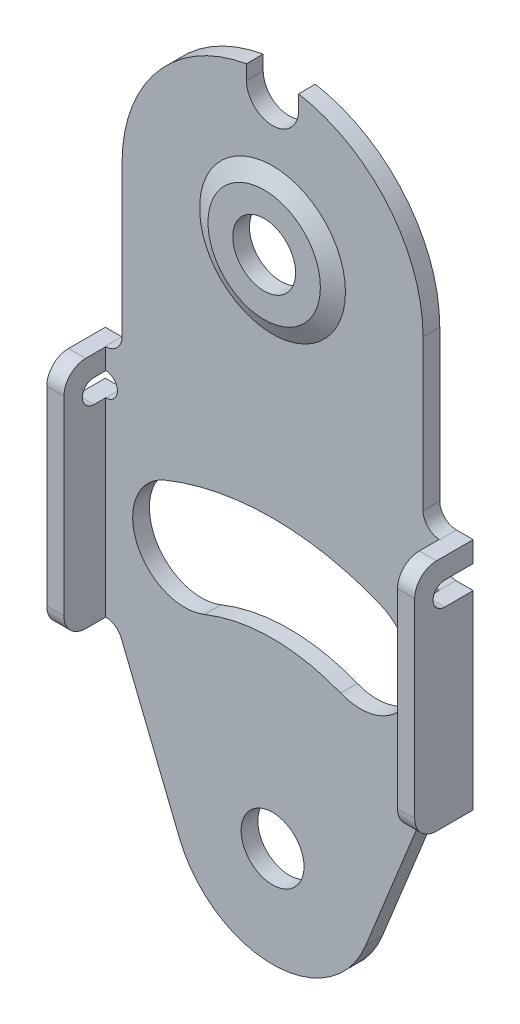
from build123d import *

# Parameters (mm, degrees)
SKETCH1_R          = 2.3876
EXTRUDE1_DEPTH     = 1.27
SKETCH2_W          = 1.303146297
SKETCH2_H          = 17.78
EXTRUDE2_DEPTH     = 3.175
SKETCH3_R          = 5.5372
SKETCH3_R_2        = 2.3876
EXTRUDE3_DEPTH     = 0.635
CUT_EXTRUDE1_DEPTH = 2.27
CUT_EXTRUDE2_DEPTH = 1.3208
SKETCH7_W          = 0.407051282
SKETCH7_H          = 0.108547009
SKETCH7_W_2        = 0.094978633
SKETCH7_H_2        = 1.058333333
CUT_EXTRUDE3_DEPTH = 0.00254
FILLET1_R          = 1.651


with BuildPart() as part:
    # Sketch1 → Extrude1 (new body)
    with BuildSketch(Plane.XY):
        with BuildLine():
            Line((12.666853703, 8.89), (13.97, 8.89))
            Line((13.97, 8.89), (13.97, 26.67))
            Line((13.97, 26.67), (12.7, 26.67))
            ThreePointArc((12.7, 26.67), (11.801974389, 27.041974387), (11.43, 27.939999996))
            Line((11.43, 27.939999996), (11.43, 39.37))
            ThreePointArc((11.43, 39.37), (8.754713473, 46.71846188), (1.9812, 50.626986567))
            Line((1.9812, 50.626986567), (1.9812, 49.53))
            ThreePointArc((1.9812, 49.53), (0, 47.5488), (-1.9812, 49.53))
            Line((-1.9812, 49.53), (-1.9812, 50.626986567))
            ThreePointArc((-1.9812, 50.626986567), (-8.754713473, 46.71846188), (-11.43, 39.37))
            Line((-11.43, 39.37), (-11.43, 27.939999996))
            ThreePointArc((-11.43, 27.939999996), (-11.801974389, 27.041974387), (-12.7, 26.67))
            Line((-12.7, 26.67), (-13.97, 26.67))
            Line((-13.97, 26.67), (-13.97, 8.89))
            Line((-13.97, 8.89), (-12.666853703, 8.89))
            ThreePointArc((-12.666853703, 8.89), (-11.956678716, 8.672877717), (-11.489330208, 8.095750374))
            Line((-11.489330208, 8.095750374), (-7.065140972, -2.854502242))
            ThreePointArc((-7.065140972, -2.854502242), (0, -7.62), (7.065140972, -2.854502242))
            Line((7.065140972, -2.854502242), (11.489330208, 8.095750374))
            ThreePointArc((11.489330208, 8.095750374), (11.956678716, 8.672877717), (12.666853703, 8.89))
        make_face()
        Circle(SKETCH1_R, mode=Mode.SUBTRACT)
        with Locations((0, 39.37)):
            Circle(SKETCH1_R, mode=Mode.SUBTRACT)
    extrude(amount=EXTRUDE1_DEPTH)

    # Sketch2 → Extrude2 (add)
    with BuildSketch(Plane.XY.offset(1.27)):
        with Locations((-13.318426851, 17.78)):
            Rectangle(SKETCH2_W, SKETCH2_H)
        with Locations((13.318426851, 17.78)):
            Rectangle(SKETCH2_W, SKETCH2_H)
    extrude(amount=EXTRUDE2_DEPTH)

    # Sketch3 → Extrude3 (add)
    with BuildSketch(Plane.XY.offset(1.27)):
        with Locations((0, 39.37)):
            Circle(SKETCH3_R)
        with Locations((0, 39.37)):
            Circle(SKETCH3_R_2, mode=Mode.SUBTRACT)
    extrude(amount=EXTRUDE3_DEPTH)

    # Sketch4 → Cut-Revolve1 (revolve, cut)
    with BuildSketch(Plane(origin=(0, 0, 0), x_dir=(0, 0, -1), z_dir=(1, 0, 0))):
        Polygon((-1.905, 43.6372), (-1.27, 44.9072), (-1.905, 44.9072), align=None)
        Polygon((-0.635, 43.3324), (-0.635, 41.7576), (0, 41.7576), (0, 43.3324), (0, 44.5389), align=None)
    revolve(axis=Axis((0, 39.37, 6.286624189), (0, 0, -1)), mode=Mode.SUBTRACT)

    # Sketch5 → Cut-Extrude1 (cut, through all)
    with BuildSketch(Plane.XY.offset(1.27)):
        with BuildLine():
            Line((-12.666853703, 25.0952), (-12.666853703, 23.3172))
            ThreePointArc((-12.666853703, 23.3172), (-11.777853703, 24.2062), (-12.666853703, 25.0952))
        make_face()
        with BuildLine():
            Line((12.666853703, 25.0952), (12.666853703, 23.3172))
            ThreePointArc((12.666853703, 23.3172), (11.777853703, 24.2062), (12.666853703, 25.0952))
        make_face()
        with BuildLine():
            ThreePointArc((5.176164065, 12.811455629), (0, 13.8176), (-5.176164065, 12.811455629))
            ThreePointArc((-5.176164065, 12.811455629), (-10.334378536, 15.000987768), (-8.144846397, 20.15920224))
            ThreePointArc((-8.144846397, 20.15920224), (0, 21.7424), (8.144846397, 20.15920224))
            ThreePointArc((8.144846397, 20.15920224), (10.334378536, 15.000987768), (5.176164065, 12.811455629))
        make_face()
    extrude(amount=-CUT_EXTRUDE1_DEPTH, mode=Mode.SUBTRACT)

    # Sketch6 → Cut-Extrude2 (cut)
    with BuildSketch(Plane(origin=(13.97, 0, 0), x_dir=(0, 0, -1), z_dir=(1, 0, 0))):
        with BuildLine():
            Line((0, 25.0952), (-2.159, 25.0952))
            ThreePointArc((-2.159, 25.0952), (-3.048, 24.2062), (-2.159, 23.3172))
            Line((-2.159, 23.3172), (0, 23.3172))
            Line((0, 23.3172), (0, 25.0952))
        make_face()
    cut_extrude2 = extrude(amount=-CUT_EXTRUDE2_DEPTH, mode=Mode.SUBTRACT)

    # Mirror2: Cut-Extrude2 across plane
    add(cut_extrude2.mirror(Plane(origin=(0, 0, 0), x_dir=(0, 0, 1), z_dir=(1, 0, 0))), mode=Mode.SUBTRACT)

    # Sketch7 → Cut-Extrude3 (cut)
    with BuildSketch(Plane(origin=(0, 0, 0), x_dir=(-1, 0, 0), z_dir=(0, 0, -1))):
        Polygon((-7.47529818, 7.634015825), (-7.377139459, 7.634015825), (-7.170009718, 6.857862313), (-6.861965181, 7.634015825), (-6.848184799, 7.634015825), (-6.545864419, 6.86316246), (-6.337674649, 7.634015825), (-6.240575958, 7.634015825), (-6.525935867, 6.575682492), (-6.539504243, 6.575682492), (-6.857937069, 7.385120926), (-7.180186, 6.575682492), (-7.193754377, 6.575682492), align=None)
        Polygon((-6.118460573, 7.634015825), (-6.020301853, 7.634015825), (-5.813172112, 6.857862313), (-5.505127574, 7.634015825), (-5.491347192, 7.634015825), (-5.189026812, 6.86316246), (-4.980837042, 7.634015825), (-4.883738351, 7.634015825), (-5.16909826, 6.575682492), (-5.182666636, 6.575682492), (-5.501099462, 7.385120926), (-5.823348394, 6.575682492), (-5.83691677, 6.575682492), align=None)
        Polygon((-4.761622966, 7.634015825), (-4.663464246, 7.634015825), (-4.456334505, 6.857862313), (-4.148289967, 7.634015825), (-4.134509585, 7.634015825), (-3.832189206, 6.86316246), (-3.623999435, 7.634015825), (-3.526900744, 7.634015825), (-3.812260653, 6.575682492), (-3.825829029, 6.575682492), (-4.144261855, 7.385120926), (-4.466510787, 6.575682492), (-4.480079163, 6.575682492), align=None)
        with BuildLine():
            add(Edge.make_bspline(
                [(-3.262317411, 6.738503004), (-3.256423942, 6.738152797), (-3.244870485, 6.737466256), (-3.228167225, 6.732756167), (-3.213049792, 6.724392714), (-3.199584089, 6.713246112), (-3.18848475, 6.699730995), (-3.179823244, 6.684734137), (-3.175154184, 6.667891036), (-3.174472644, 6.656270635), (-3.174122966, 6.65030856)],
                knots=[0, 0, 0, 0, 1.7678e-05, 3.4656e-05, 5.1542e-05, 6.9159e-05, 8.6776e-05, 0.000103764, 0.000120742, 0.000138631, 0.000138631, 0.000138631, 0.000138631], degree=3))
            add(Edge.make_bspline(
                [(-3.174122966, 6.65030856), (-3.174484493, 6.644489744), (-3.175197419, 6.633015123), (-3.179812541, 6.616299062), (-3.188550761, 6.601292831), (-3.199507533, 6.587594328), (-3.213053121, 6.576424112), (-3.228202965, 6.568131815), (-3.244831274, 6.563084478), (-3.2564174, 6.562441526), (-3.262317411, 6.562114116)],
                knots=[0, 0, 0, 0, 1.7467e-05, 3.4445e-05, 5.1433e-05, 6.9214e-05, 8.6831e-05, 0.000103717, 0.000120754, 0.000138432, 0.000138432, 0.000138432, 0.000138432], degree=3))
            add(Edge.make_bspline(
                [(-3.262317411, 6.562114116), (-3.268221673, 6.562429679), (-3.279748339, 6.563045743), (-3.29631458, 6.568235449), (-3.311556687, 6.576346352), (-3.325099638, 6.587615156), (-3.336148176, 6.601222342), (-3.344501565, 6.616402409), (-3.34951811, 6.632967272), (-3.350177867, 6.644480319), (-3.350511855, 6.65030856)],
                knots=[0, 0, 0, 0, 1.7678e-05, 3.4512e-05, 5.1585e-05, 6.9202e-05, 8.6983e-05, 0.000103869, 0.000120906, 0.000138373, 0.000138373, 0.000138373, 0.000138373], degree=3))
            add(Edge.make_bspline(
                [(-3.350511855, 6.65030856), (-3.350190697, 6.656280396), (-3.349563674, 6.667939674), (-3.344491034, 6.684630832), (-3.336212989, 6.699800813), (-3.325023262, 6.713225493), (-3.311559963, 6.724470225), (-3.296351349, 6.732654103), (-3.27970844, 6.737504418), (-3.268214959, 6.738164369), (-3.262317411, 6.738503004)],
                knots=[0, 0, 0, 0, 1.7889e-05, 3.4926e-05, 5.1812e-05, 6.9429e-05, 8.7046e-05, 0.000104119, 0.000120893, 0.000138571, 0.000138571, 0.000138571, 0.000138571], degree=3))
        make_face()
        Polygon((-3.02487083, 7.634015825), (-2.916111815, 7.634015825), (-2.637960106, 7.179263221), (-2.360232408, 7.634015825), (-2.251473394, 7.634015825), (-2.590682795, 7.078772436), (-2.590682795, 6.575682492), (-2.685661428, 6.575682492), (-2.685661428, 7.078772436), align=None)
        with BuildLine():
            add(Edge.make_bspline(
                [(-1.566270402, 7.661152577), (-1.546673665, 7.660656225), (-1.508184058, 7.659681349), (-1.451616172, 7.652218858), (-1.397612417, 7.639308585), (-1.345732875, 7.622114302), (-1.296598094, 7.599177381), (-1.249838238, 7.571453538), (-1.205564564, 7.538652324), (-1.164373813, 7.501027295), (-1.126679926, 7.460089918), (-1.09347067, 7.41640255), (-1.065638834, 7.37022934), (-1.042783131, 7.321709042), (-1.024852361, 7.270951385), (-1.012479222, 7.21768577), (-1.004575543, 7.162257318), (-1.003651534, 7.124451576), (-1.003182795, 7.10527317)],
                knots=[0, 0, 0, 0, 5.8781e-05, 0.00011545, 0.000170782, 0.000225153, 0.000279125, 0.000333119, 0.000387987, 0.000444118, 0.000500236, 0.000554722, 0.00060846, 0.000661664, 0.000715372, 0.000769623, 0.000825481, 0.00088299, 0.00088299, 0.00088299, 0.00088299], degree=3))
            add(Edge.make_bspline(
                [(-1.003182795, 7.10527317), (-1.003651465, 7.086236037), (-1.004575268, 7.048711644), (-1.012488208, 6.993634936), (-1.024898225, 6.940690844), (-1.04261662, 6.889967754), (-1.065363372, 6.841412157), (-1.09338053, 6.795151816), (-1.126382754, 6.751171566), (-1.16394054, 6.709953212), (-1.204883236, 6.672156358), (-1.248798102, 6.639221364), (-1.294697511, 6.610880974), (-1.343172113, 6.588267816), (-1.393579029, 6.570193926), (-1.446369398, 6.557871107), (-1.501295856, 6.549922405), (-1.538752088, 6.549009664), (-1.557790167, 6.54854574)],
                knots=[0, 0, 0, 0, 5.7086e-05, 0.000112524, 0.000166569, 0.000220006, 0.000273402, 0.00032714, 0.000381965, 0.000438096, 0.000494214, 0.00054887, 0.000602537, 0.000655741, 0.000709049, 0.000762887, 0.000818115, 0.000875201, 0.000875201, 0.000875201, 0.000875201], degree=3))
            add(Edge.make_bspline(
                [(-1.557790167, 6.54854574), (-1.576968473, 6.549014245), (-1.614774019, 6.549937793), (-1.670272123, 6.557854551), (-1.723575155, 6.570234421), (-1.774530685, 6.58792656), (-1.823167128, 6.610791771), (-1.869579605, 6.638672619), (-1.913581824, 6.671755254), (-1.954808971, 6.709300861), (-1.992530752, 6.750174164), (-2.025417516, 6.793969284), (-2.053304633, 6.839827005), (-2.07609307, 6.88787459), (-2.094134466, 6.937879764), (-2.106442827, 6.99017609), (-2.114406318, 7.044465416), (-2.115323997, 7.08142934), (-2.115789633, 7.100185029)],
                knots=[0, 0, 0, 0, 5.751e-05, 0.000113367, 0.000167825, 0.000221463, 0.000274858, 0.000328778, 0.000383603, 0.000439735, 0.000495852, 0.000550211, 0.000603768, 0.000656588, 0.000709497, 0.000762923, 0.000817521, 0.00087376, 0.00087376, 0.00087376, 0.00087376], degree=3))
            add(Edge.make_bspline(
                [(-2.115789633, 7.100185029), (-2.115627969, 7.112773955), (-2.115306682, 7.137792993), (-2.111438717, 7.174945512), (-2.105826013, 7.211500544), (-2.097782101, 7.247354141), (-2.087261764, 7.282418534), (-2.074848412, 7.31693555), (-2.059687078, 7.35055539), (-2.04254793, 7.383437321), (-2.023418764, 7.415068759), (-2.002289668, 7.444968061), (-1.979902783, 7.473386125), (-1.955360519, 7.499586528), (-1.929471737, 7.524331467), (-1.901816465, 7.54724067), (-1.872563453, 7.568520714), (-1.841586829, 7.587697817), (-1.809649874, 7.605042127), (-1.776727611, 7.619925877), (-1.743267171, 7.632700282), (-1.709111837, 7.643054055), (-1.674352308, 7.651228028), (-1.638912721, 7.656794061), (-1.602821309, 7.66067189), (-1.578506458, 7.660991659), (-1.566270402, 7.661152577)],
                knots=[0, 0, 0, 0, 3.7752e-05, 7.5028e-05, 0.000111939, 0.000148663, 0.000185154, 0.000221705, 0.000258622, 0.0002957, 0.000332895, 0.000369421, 0.000405477, 0.000441331, 0.000477021, 0.000512852, 0.000548983, 0.000585456, 0.000622071, 0.000657934, 0.000693765, 0.000729444, 0.000764928, 0.000800792, 0.000837013, 0.000873706, 0.000873706, 0.000873706, 0.000873706], degree=3))
        make_face()
        with BuildLine():
            add(Edge.make_bspline(
                [(-1.561606273, 7.552605569), (-1.571649745, 7.552483137), (-1.591640674, 7.552239446), (-1.621360046, 7.549029456), (-1.650688559, 7.544454465), (-1.679632271, 7.537928625), (-1.708070078, 7.529037399), (-1.736267053, 7.518804553), (-1.763966072, 7.50634008), (-1.791075691, 7.492257382), (-1.817357154, 7.47666997), (-1.842156233, 7.459442793), (-1.865537128, 7.440979849), (-1.887442592, 7.42123805), (-1.907808303, 7.400116861), (-1.927035106, 7.377936482), (-1.944352337, 7.354062934), (-1.960222975, 7.329143597), (-1.974425155, 7.303210928), (-1.987054203, 7.276537946), (-1.997384749, 7.248907074), (-2.005809801, 7.220618079), (-2.012794743, 7.191715763), (-2.017219763, 7.161980876), (-2.020465024, 7.13156283), (-2.020694787, 7.111006412), (-2.020811, 7.100609041)],
                knots=[0, 0, 0, 0, 3.0117e-05, 5.9946e-05, 8.9572e-05, 0.000119144, 0.000148853, 0.000178903, 0.000209082, 0.0002399, 0.000270514, 0.000300683, 0.000330416, 0.000359836, 0.000389072, 0.000418391, 0.00044782, 0.000477462, 0.00050697, 0.000536467, 0.00056592, 0.000595365, 0.000624985, 0.00065503, 0.000685492, 0.000716668, 0.000716668, 0.000716668, 0.000716668], degree=3))
            add(Edge.make_bspline(
                [(-2.020811, 7.100609041), (-2.020425507, 7.085319988), (-2.019667121, 7.055241692), (-2.01302757, 7.011164182), (-2.002800449, 6.968804153), (-1.987724531, 6.928393385), (-1.968870893, 6.889584518), (-1.945579428, 6.85272183), (-1.917984419, 6.817795356), (-1.886638543, 6.785048929), (-1.852371915, 6.755159841), (-1.81598559, 6.728924239), (-1.77786938, 6.706726377), (-1.737923888, 6.688642463), (-1.69636237, 6.674312708), (-1.652917015, 6.664491789), (-1.607877233, 6.658028259), (-1.577176297, 6.657407544), (-1.561606273, 6.657092748)],
                knots=[0, 0, 0, 0, 4.5842e-05, 9.0186e-05, 0.00013343, 0.000176357, 0.000219309, 0.000262659, 0.000306895, 0.00035263, 0.000398461, 0.000443118, 0.000487007, 0.000530556, 0.00057447, 0.000618645, 0.000664009, 0.00071069, 0.00071069, 0.00071069, 0.00071069], degree=3))
            add(Edge.make_bspline(
                [(-1.561606273, 6.657092748), (-1.551141019, 6.657236532), (-1.530385277, 6.657521697), (-1.499513536, 6.660393916), (-1.469197967, 6.664999743), (-1.439481092, 6.671631156), (-1.410396637, 6.679930668), (-1.381823208, 6.689790624), (-1.354065154, 6.702091845), (-1.326772298, 6.71568325), (-1.30064772, 6.731177297), (-1.27570869, 6.747819786), (-1.252583811, 6.766255535), (-1.230694734, 6.785704017), (-1.210245409, 6.806557371), (-1.191374121, 6.828788485), (-1.174144415, 6.852537684), (-1.158279802, 6.877419223), (-1.144127387, 6.903422852), (-1.131796564, 6.93019254), (-1.121335358, 6.957662371), (-1.11289031, 6.985871965), (-1.106272563, 7.014767746), (-1.101712683, 7.044388403), (-1.098523036, 7.07467468), (-1.09828262, 7.095159132), (-1.098161428, 7.105485176)],
                knots=[0, 0, 0, 0, 3.1388e-05, 6.2252e-05, 9.2926e-05, 0.000123326, 0.000153524, 0.00018363, 0.000213918, 0.000244542, 0.000275048, 0.000304978, 0.000334413, 0.000363692, 0.000392777, 0.000421958, 0.00045109, 0.000480732, 0.000510427, 0.000539834, 0.000569089, 0.000598533, 0.000628106, 0.000657941, 0.000688403, 0.000719368, 0.000719368, 0.000719368, 0.000719368], degree=3))
            add(Edge.make_bspline(
                [(-1.098161428, 7.105485176), (-1.098282717, 7.115740578), (-1.098523316, 7.136084058), (-1.101711159, 7.166159115), (-1.106277381, 7.195566634), (-1.112858009, 7.224191165), (-1.121339841, 7.252040005), (-1.131798391, 7.279086997), (-1.144131089, 7.305432904), (-1.158285004, 7.331012608), (-1.174195027, 7.355558303), (-1.191580191, 7.379023794), (-1.210740666, 7.400968409), (-1.231129011, 7.4219339), (-1.253254493, 7.441473119), (-1.277016887, 7.459592547), (-1.302127713, 7.476729466), (-1.328715235, 7.492188862), (-1.356154478, 7.506465547), (-1.384310365, 7.51869716), (-1.412863926, 7.529090634), (-1.44174255, 7.537955526), (-1.471189308, 7.544428906), (-1.501005228, 7.549033578), (-1.531149058, 7.552238328), (-1.551421651, 7.552482767), (-1.561606273, 7.552605569)],
                knots=[0, 0, 0, 0, 3.0753e-05, 6.1003e-05, 9.063e-05, 0.000119995, 0.000149034, 0.000177893, 0.000206916, 0.000236238, 0.000265524, 0.000294611, 0.000323769, 0.000352853, 0.000382291, 0.000412228, 0.000442452, 0.000473431, 0.000504437, 0.000535198, 0.000565447, 0.000595561, 0.000625754, 0.000655799, 0.00068605, 0.000716591, 0.000716591, 0.000716591, 0.000716591], degree=3))
        make_face(mode=Mode.SUBTRACT)
        with BuildLine():
            Line((-0.786088778, 7.634015825), (-0.574294908, 7.634015825))
            add(Edge.make_bspline(
                [(-0.574294908, 7.634015825), (-0.560161281, 7.633968779), (-0.533023152, 7.633878445), (-0.494145044, 7.63337475), (-0.458818755, 7.631931076), (-0.427062756, 7.630688718), (-0.398877629, 7.628423298), (-0.374176949, 7.626258055), (-0.353074478, 7.623423638), (-0.340300137, 7.620791284), (-0.334516262, 7.619599425)],
                knots=[0, 0, 0, 0, 4.2402e-05, 8.1416e-05, 0.000116632, 0.000148467, 0.000176744, 0.000201447, 0.000222854, 0.000240566, 0.000240566, 0.000240566, 0.000240566], degree=3))
            add(Edge.make_bspline(
                [(-0.334516262, 7.619599425), (-0.326773307, 7.617686332), (-0.311452574, 7.613900957), (-0.289393864, 7.605900078), (-0.268374056, 7.596641286), (-0.248480467, 7.585766542), (-0.229812739, 7.573195121), (-0.212178393, 7.559144046), (-0.195497408, 7.5436902), (-0.180444391, 7.52644395), (-0.166250916, 7.50835053), (-0.154280069, 7.488785346), (-0.143960872, 7.468325789), (-0.135745025, 7.446763784), (-0.129129542, 7.424308439), (-0.124464941, 7.40075635), (-0.121667559, 7.376214817), (-0.121382759, 7.35947564), (-0.121238351, 7.35098798)],
                knots=[0, 0, 0, 0, 2.3913e-05, 4.7315e-05, 7.0283e-05, 9.277e-05, 0.000115231, 0.000137713, 0.000160362, 0.000183338, 0.000206321, 0.000229265, 0.00025202, 0.000274974, 0.000298388, 0.00032217, 0.000346917, 0.000372372, 0.000372372, 0.000372372, 0.000372372], degree=3))
            add(Edge.make_bspline(
                [(-0.121238351, 7.35098798), (-0.121682548, 7.336886413), (-0.122549291, 7.309370603), (-0.130630454, 7.269437908), (-0.143867639, 7.232187805), (-0.162108253, 7.197667198), (-0.185336999, 7.166548979), (-0.213254258, 7.139216627), (-0.245875602, 7.116344559), (-0.276243514, 7.100483829), (-0.303068998, 7.090325974), (-0.325152881, 7.083178789), (-0.349242658, 7.077656719), (-0.375107518, 7.072709726), (-0.4028551, 7.068974809), (-0.432418897, 7.066239291), (-0.463819996, 7.064529615), (-0.485391571, 7.064275009), (-0.496488752, 7.06414403)],
                knots=[0, 0, 0, 0, 4.2266e-05, 8.2472e-05, 0.000121632, 0.000160517, 0.000199144, 0.000237674, 0.000277205, 0.000318263, 0.000340075, 0.000363206, 0.000387838, 0.000414158, 0.000442192, 0.000471789, 0.000503212, 0.000536503, 0.000536503, 0.000536503, 0.000536503], degree=3))
            Line((-0.496488752, 7.06414403), (-0.107669975, 6.575682492))
            Line((-0.107669975, 6.575682492), (-0.22512123, 6.575682492))
            Line((-0.22512123, 6.575682492), (-0.613940007, 7.06414403))
            Line((-0.613940007, 7.06414403), (-0.691110146, 7.06414403))
            Line((-0.691110146, 7.06414403), (-0.691110146, 6.575682492))
            Line((-0.691110146, 6.575682492), (-0.786088778, 6.575682492))
            Line((-0.786088778, 6.575682492), (-0.786088778, 7.634015825))
        make_face()
        with BuildLine():
            Line((-0.691110146, 7.525468816), (-0.691110146, 7.172691039))
            Line((-0.691110146, 7.172691039), (-0.497336775, 7.171206998))
            add(Edge.make_bspline(
                [(-0.497336775, 7.171206998), (-0.488289525, 7.171202995), (-0.470753378, 7.171195237), (-0.445383415, 7.172402879), (-0.421761381, 7.173776692), (-0.39997763, 7.175878041), (-0.38002243, 7.178586187), (-0.361905755, 7.181973756), (-0.345598032, 7.185920451), (-0.326578712, 7.192029038), (-0.305340523, 7.201707048), (-0.282259344, 7.215787568), (-0.262603875, 7.233497754), (-0.245997759, 7.253749252), (-0.23265386, 7.276015451), (-0.223246167, 7.300029448), (-0.217276429, 7.325185003), (-0.216572321, 7.342474573), (-0.216216983, 7.351199986)],
                knots=[0, 0, 0, 0, 2.7138e-05, 5.26e-05, 7.618e-05, 9.8119e-05, 0.000118237, 0.000136574, 0.000153388, 0.00016854, 0.000196438, 0.000223203, 0.000249331, 0.00027539, 0.000301532, 0.000326846, 0.00035251, 0.000378656, 0.000378656, 0.000378656, 0.000378656], degree=3))
            add(Edge.make_bspline(
                [(-0.216216983, 7.351199986), (-0.216580482, 7.359710974), (-0.217300803, 7.376576646), (-0.22318174, 7.401267838), (-0.233126863, 7.424571416), (-0.246529063, 7.446392582), (-0.262857379, 7.466200268), (-0.28200348, 7.48314786), (-0.30344386, 7.497132817), (-0.323483008, 7.506069499), (-0.341394306, 7.511548597), (-0.356945656, 7.515404306), (-0.37451746, 7.518502039), (-0.394195039, 7.520984), (-0.415894389, 7.523117281), (-0.439725229, 7.524554128), (-0.465529446, 7.525404987), (-0.483414351, 7.525447045), (-0.492672646, 7.525468816)],
                knots=[0, 0, 0, 0, 2.5512e-05, 5.0556e-05, 7.5638e-05, 0.000101235, 0.000127131, 0.000152361, 0.000177647, 0.00020365, 0.000217865, 0.000233805, 0.000251687, 0.000271357, 0.000293296, 0.000317087, 0.000342966, 0.000370739, 0.000370739, 0.000370739, 0.000370739], degree=3))
            Line((-0.492672646, 7.525468816), (-0.691110146, 7.525468816))
        make_face(mode=Mode.SUBTRACT)
        Polygon((0.109424042, 7.634015825), (0.204402675, 7.634015825), (0.204402675, 7.230992655), (0.645586903, 7.634015825), (0.781058658, 7.634015825), (0.261008244, 7.159122663), (0.821763786, 6.575682492), (0.695196278, 6.575682492), (0.204402675, 7.086404647), (0.204402675, 6.575682492), (0.109424042, 6.575682492), align=None)
        with Locations((1.086347119, 6.982733774)):
            Rectangle(SKETCH7_W, SKETCH7_H)
        with Locations((1.513750966, 7.104849159)):
            Rectangle(SKETCH7_W_2, SKETCH7_H_2)
        Polygon((1.832607803, 6.575682492), (1.832607803, 7.634015825), (1.852536355, 7.634015825), (2.551731735, 6.801044738), (2.551731735, 7.634015825), (2.646710367, 7.634015825), (2.646710367, 6.575682492), (2.625085768, 6.575682492), (1.927586435, 7.406745526), (1.927586435, 6.575682492), align=None)
        with BuildLine():
            Line((2.918077888, 6.575682492), (2.918077888, 7.634015825))
            Line((2.918077888, 7.634015825), (3.131779811, 7.634015825))
            add(Edge.make_bspline(
                [(3.131779811, 7.634015825), (3.150366863, 7.633882), (3.186276949, 7.633623452), (3.238169284, 7.631984126), (3.286182469, 7.629084152), (3.330158596, 7.624860033), (3.370218391, 7.619673283), (3.406249684, 7.61317197), (3.438438785, 7.605495071), (3.458235497, 7.598949899), (3.467597119, 7.595854767)],
                knots=[0, 0, 0, 0, 5.5761e-05, 0.00010773, 0.000155735, 0.000200036, 0.000240244, 0.000276879, 0.000309839, 0.000339409, 0.000339409, 0.000339409, 0.000339409], degree=3))
            add(Edge.make_bspline(
                [(3.467597119, 7.595854767), (3.479841957, 7.591188816), (3.50405396, 7.581962721), (3.538527543, 7.564558792), (3.570980688, 7.544839592), (3.60158743, 7.522779129), (3.629648632, 7.497752766), (3.656260543, 7.4708236), (3.680334519, 7.441012364), (3.702380599, 7.408937308), (3.722257811, 7.374976283), (3.739535604, 7.339194), (3.753884787, 7.301772177), (3.765796549, 7.262814883), (3.775184406, 7.222236454), (3.781589419, 7.179989642), (3.78581398, 7.136241411), (3.786238539, 7.106555323), (3.786453957, 7.091492788)],
                knots=[0, 0, 0, 0, 3.929e-05, 7.7689e-05, 0.000115648, 0.000153134, 0.000190689, 0.000228319, 0.000266595, 0.000305467, 0.000344991, 0.000384532, 0.000424533, 0.000465106, 0.00050666, 0.000549358, 0.000593216, 0.000638392, 0.000638392, 0.000638392, 0.000638392], degree=3))
            add(Edge.make_bspline(
                [(3.786453957, 7.091492788), (3.786263769, 7.078411414), (3.785888984, 7.052633199), (3.782523691, 7.014641785), (3.77763228, 6.977777443), (3.770059392, 6.94221572), (3.760866251, 6.907645044), (3.749084233, 6.874433866), (3.73558731, 6.842277523), (3.719848418, 6.81161081), (3.702569951, 6.782557029), (3.684027424, 6.755168714), (3.664240614, 6.729836683), (3.643020839, 6.706484222), (3.620642315, 6.685146535), (3.59695853, 6.665645378), (3.571908369, 6.648362324), (3.545604032, 6.632618223), (3.517278154, 6.618883972), (3.486394214, 6.607263469), (3.452820501, 6.597633659), (3.416639423, 6.589599127), (3.377788467, 6.583225752), (3.336229541, 6.5789542), (3.292026499, 6.576065575), (3.261673721, 6.575812666), (3.246050979, 6.575682492)],
                knots=[0, 0, 0, 0, 3.9235e-05, 7.7317e-05, 0.000114346, 0.000150727, 0.000186317, 0.000221585, 0.000256355, 0.000290867, 0.000324899, 0.000357711, 0.000390028, 0.000421245, 0.000452286, 0.000482716, 0.00051318, 0.000543503, 0.000574604, 0.000607482, 0.00064237, 0.0006793, 0.000718615, 0.000760406, 0.000804589, 0.00085145, 0.00085145, 0.00085145, 0.00085145], degree=3))
            Line((3.246050979, 6.575682492), (2.918077888, 6.575682492))
        make_face()
        with BuildLine():
            Line((3.013056521, 6.6842295), (3.134535888, 6.6842295))
            add(Edge.make_bspline(
                [(3.134535888, 6.6842295), (3.151991848, 6.68430452), (3.185566051, 6.68444881), (3.233843588, 6.68571494), (3.277954739, 6.687783812), (3.317905767, 6.690679133), (3.353674115, 6.694509881), (3.385334534, 6.698780983), (3.412783243, 6.704102117), (3.429392859, 6.708925383), (3.437068273, 6.711154246)],
                knots=[0, 0, 0, 0, 5.2367e-05, 0.000100721, 0.000144869, 0.000184837, 0.000220869, 0.00025277, 0.000280668, 0.000304636, 0.000304636, 0.000304636, 0.000304636], degree=3))
            add(Edge.make_bspline(
                [(3.437068273, 6.711154246), (3.446728849, 6.714556503), (3.465819259, 6.721279754), (3.493299968, 6.733543619), (3.518928872, 6.748070625), (3.543152617, 6.764218456), (3.565627582, 6.782556652), (3.586620113, 6.802686451), (3.606087943, 6.824710299), (3.623829936, 6.848600862), (3.639707447, 6.874209444), (3.653457081, 6.901284281), (3.665507425, 6.929528722), (3.674965476, 6.959376491), (3.682378521, 6.990560754), (3.687629272, 7.023083704), (3.690899439, 7.056939268), (3.691280877, 7.07996622), (3.691475324, 7.091704794)],
                knots=[0, 0, 0, 0, 3.072e-05, 6.0706e-05, 9.0132e-05, 0.000119003, 0.000147941, 0.00017703, 0.000206168, 0.000236019, 0.0002662, 0.000296446, 0.000327041, 0.000358217, 0.000390253, 0.00042312, 0.000456979, 0.000492188, 0.000492188, 0.000492188, 0.000492188], degree=3))
            add(Edge.make_bspline(
                [(3.691475324, 7.091704794), (3.691320116, 7.104082299), (3.691015208, 7.128398016), (3.687182738, 7.164076155), (3.681582172, 7.198390542), (3.673483296, 7.231343473), (3.663162768, 7.262999237), (3.65028296, 7.293182755), (3.635567101, 7.322212799), (3.618058235, 7.349419333), (3.598882567, 7.375149869), (3.577601637, 7.39872195), (3.554553545, 7.420189274), (3.529989673, 7.439886162), (3.503217741, 7.457020178), (3.474868411, 7.472346865), (3.444525791, 7.485354051), (3.423415762, 7.492272183), (3.412687597, 7.495787994)],
                knots=[0, 0, 0, 0, 3.7116e-05, 7.2915e-05, 0.000107525, 0.000141359, 0.000174612, 0.000207294, 0.000239722, 0.000272128, 0.000304226, 0.0003359, 0.000367249, 0.000398637, 0.000430215, 0.000462465, 0.00049523, 0.000529088, 0.000529088, 0.000529088, 0.000529088], degree=3))
            add(Edge.make_bspline(
                [(3.412687597, 7.495787994), (3.40381237, 7.498242247), (3.384941201, 7.503460663), (3.354146887, 7.509153097), (3.319489449, 7.514173981), (3.280815015, 7.518424864), (3.238167672, 7.521475078), (3.191514618, 7.523764499), (3.14083569, 7.525308648), (3.105704305, 7.52541409), (3.087470583, 7.525468816)],
                knots=[0, 0, 0, 0, 2.7614e-05, 5.8714e-05, 9.3854e-05, 0.000132671, 0.000175403, 0.000222102, 0.000272793, 0.000327492, 0.000327492, 0.000327492, 0.000327492], degree=3))
            Line((3.087470583, 7.525468816), (3.013056521, 7.525468816))
            Line((3.013056521, 7.525468816), (3.013056521, 6.6842295))
        make_face(mode=Mode.SUBTRACT)
        with BuildLine():
            add(Edge.make_bspline(
                [(4.078174042, 6.738503004), (4.084067511, 6.738152797), (4.095620968, 6.737466256), (4.112324228, 6.732756167), (4.127441661, 6.724392714), (4.140907364, 6.713246112), (4.152006703, 6.699730995), (4.160668209, 6.684734137), (4.165337269, 6.667891036), (4.166018809, 6.656270635), (4.166368487, 6.65030856)],
                knots=[0, 0, 0, 0, 1.7678e-05, 3.4656e-05, 5.1542e-05, 6.9159e-05, 8.6776e-05, 0.000103764, 0.000120742, 0.000138631, 0.000138631, 0.000138631, 0.000138631], degree=3))
            add(Edge.make_bspline(
                [(4.166368487, 6.65030856), (4.16600696, 6.644489744), (4.165294034, 6.633015123), (4.160678912, 6.616299062), (4.151940692, 6.601292831), (4.14098392, 6.587594328), (4.127438332, 6.576424112), (4.112288488, 6.568131815), (4.095660179, 6.563084478), (4.084074053, 6.562441526), (4.078174042, 6.562114116)],
                knots=[0, 0, 0, 0, 1.7467e-05, 3.4445e-05, 5.1433e-05, 6.9214e-05, 8.6831e-05, 0.000103717, 0.000120754, 0.000138432, 0.000138432, 0.000138432, 0.000138432], degree=3))
            add(Edge.make_bspline(
                [(4.078174042, 6.562114116), (4.07226978, 6.562429679), (4.060743114, 6.563045743), (4.044176873, 6.568235449), (4.028934766, 6.576346352), (4.015391815, 6.587615156), (4.004343277, 6.601222342), (3.995989888, 6.616402409), (3.990973343, 6.632967272), (3.990313586, 6.644480319), (3.989979598, 6.65030856)],
                knots=[0, 0, 0, 0, 1.7678e-05, 3.4512e-05, 5.1585e-05, 6.9202e-05, 8.6983e-05, 0.000103869, 0.000120906, 0.000138373, 0.000138373, 0.000138373, 0.000138373], degree=3))
            add(Edge.make_bspline(
                [(3.989979598, 6.65030856), (3.990300756, 6.656280396), (3.990927779, 6.667939674), (3.996000419, 6.684630832), (4.004278464, 6.699800813), (4.015468191, 6.713225493), (4.02893149, 6.724470225), (4.044140104, 6.732654103), (4.060783013, 6.737504418), (4.072276494, 6.738164369), (4.078174042, 6.738503004)],
                knots=[0, 0, 0, 0, 1.7889e-05, 3.4926e-05, 5.1812e-05, 6.9429e-05, 8.7046e-05, 0.000104119, 0.000120893, 0.000138571, 0.000138571, 0.000138571, 0.000138571], degree=3))
        make_face()
        with BuildLine():
            Line((5.373953957, 7.439818443), (5.290847653, 7.37621668))
            add(Edge.make_bspline(
                [(5.290847653, 7.37621668), (5.284919206, 7.383282104), (5.27314224, 7.397317695), (5.254195291, 7.417026748), (5.234449318, 7.43549172), (5.213911869, 7.452800574), (5.192213278, 7.468348024), (5.16987918, 7.482944286), (5.146535961, 7.496027626), (5.11425627, 7.511891434), (5.072029421, 7.528445628), (5.01887241, 7.542325891), (4.963382149, 7.551161818), (4.92552478, 7.552118806), (4.906268994, 7.552605569)],
                knots=[0, 0, 0, 0, 2.7663e-05, 5.4954e-05, 8.1953e-05, 0.000108744, 0.00013546, 0.000161981, 0.000188751, 0.000215679, 0.000269851, 0.000324464, 0.000380234, 0.000437965, 0.000437965, 0.000437965, 0.000437965], degree=3))
            add(Edge.make_bspline(
                [(4.906268994, 7.552605569), (4.895660473, 7.552483418), (4.874541887, 7.552240251), (4.843200563, 7.549032253), (4.812444473, 7.544523387), (4.782293625, 7.537833111), (4.752786397, 7.529374724), (4.723729885, 7.519267515), (4.695544775, 7.506762599), (4.667841165, 7.492941292), (4.641298404, 7.477330136), (4.616184139, 7.460302051), (4.592589968, 7.442047586), (4.570497226, 7.422498323), (4.549883327, 7.401742302), (4.53089764, 7.379558322), (4.513605862, 7.356017308), (4.497665237, 7.331429682), (4.483389006, 7.305867065), (4.471435924, 7.279234841), (4.460851041, 7.251989076), (4.452475318, 7.22382194), (4.445845762, 7.194931627), (4.441271444, 7.165240603), (4.438099931, 7.134810895), (4.437857972, 7.114185698), (4.437736008, 7.103789129)],
                knots=[0, 0, 0, 0, 3.1812e-05, 6.3329e-05, 9.4422e-05, 0.000125029, 0.000155897, 0.000186473, 0.000217234, 0.000248333, 0.000279312, 0.000309536, 0.000339305, 0.000368743, 0.000397976, 0.000426996, 0.000456253, 0.000485538, 0.000514861, 0.000543987, 0.000573044, 0.000602489, 0.000632061, 0.000661897, 0.00069257, 0.000723746, 0.000723746, 0.000723746, 0.000723746], degree=3))
            add(Edge.make_bspline(
                [(4.437736008, 7.103789129), (4.438117558, 7.088146563), (4.438866681, 7.05743446), (4.445533677, 7.012449061), (4.455664979, 6.969353524), (4.470849213, 6.928417238), (4.489572354, 6.889135425), (4.513230825, 6.852172725), (4.54063154, 6.816970573), (4.572162138, 6.78436092), (4.606756277, 6.754572246), (4.643872908, 6.728340522), (4.683419585, 6.706473879), (4.724959662, 6.688277819), (4.768812796, 6.674290666), (4.814900129, 6.664443895), (4.863121423, 6.658020664), (4.896071694, 6.657405716), (4.912841176, 6.657092748)],
                knots=[0, 0, 0, 0, 4.6901e-05, 9.2084e-05, 0.000136152, 0.000179478, 0.00022281, 0.000266453, 0.000310856, 0.000356437, 0.00040229, 0.000447638, 0.000492529, 0.000537627, 0.000583487, 0.000630351, 0.000678868, 0.000729149, 0.000729149, 0.000729149, 0.000729149], degree=3))
            add(Edge.make_bspline(
                [(4.912841176, 6.657092748), (4.931317466, 6.657603403), (4.967683223, 6.658608494), (5.021013555, 6.667123314), (5.072066274, 6.680929399), (5.120844128, 6.700250914), (5.167209604, 6.725368274), (5.211235261, 6.755817395), (5.25295826, 6.791887914), (5.278047195, 6.819429717), (5.290847653, 6.833481637)],
                knots=[0, 0, 0, 0, 5.5402e-05, 0.000109045, 0.000161555, 0.000213797, 0.000266063, 0.000319402, 0.000374108, 0.000431094, 0.000431094, 0.000431094, 0.000431094], degree=3))
            Line((5.290847653, 6.833481637), (5.373953957, 6.770515892))
            add(Edge.make_bspline(
                [(5.373953957, 6.770515892), (5.367265862, 6.761886407), (5.353921707, 6.744668774), (5.332314164, 6.720396138), (5.309551743, 6.697565155), (5.285465373, 6.676359899), (5.260332136, 6.656356048), (5.233700747, 6.638121923), (5.205921301, 6.621403013), (5.177087923, 6.606094395), (5.147231247, 6.592512275), (5.116387049, 6.580884588), (5.08468828, 6.570868253), (5.05213349, 6.562627786), (5.018655154, 6.556195816), (4.984374082, 6.551896057), (4.949216287, 6.548950287), (4.925497095, 6.548681799), (4.913477194, 6.54854574)],
                knots=[0, 0, 0, 0, 3.2746e-05, 6.5335e-05, 9.7416e-05, 0.000129406, 0.000161556, 0.000193723, 0.000226155, 0.000258779, 0.000291607, 0.000324485, 0.000357609, 0.000391288, 0.000425175, 0.000459808, 0.000494897, 0.000530948, 0.000530948, 0.000530948, 0.000530948], degree=3))
            add(Edge.make_bspline(
                [(4.913477194, 6.54854574), (4.902094466, 6.548624961), (4.879586531, 6.548781612), (4.846355242, 6.551319243), (4.814003631, 6.554781426), (4.78262416, 6.559994513), (4.752045592, 6.566146254), (4.722545129, 6.574392563), (4.693832482, 6.583630049), (4.666023008, 6.594487033), (4.639093051, 6.606738355), (4.61312947, 6.62058485), (4.588144206, 6.63591008), (4.563891614, 6.652376238), (4.540729964, 6.670512232), (4.518458541, 6.69006619), (4.496952459, 6.710972208), (4.483646885, 6.726047366), (4.476957095, 6.733626869)],
                knots=[0, 0, 0, 0, 3.4139e-05, 6.7505e-05, 9.9931e-05, 0.000131718, 0.000162902, 0.000193452, 0.000223555, 0.000253358, 0.000282958, 0.000312265, 0.000341571, 0.000370855, 0.000400159, 0.000429756, 0.00045974, 0.000490059, 0.000490059, 0.000490059, 0.000490059], degree=3))
            add(Edge.make_bspline(
                [(4.476957095, 6.733626869), (4.466242032, 6.746792896), (4.444941266, 6.772965996), (4.417688976, 6.815385805), (4.394361025, 6.859675001), (4.375499734, 6.906066265), (4.360754813, 6.954455499), (4.350540023, 7.004867095), (4.343902276, 7.057253973), (4.343143212, 7.092885573), (4.342757376, 7.110997329)],
                knots=[0, 0, 0, 0, 5.0892e-05, 0.00010117, 0.000150956, 0.000200876, 0.000251176, 0.000302484, 0.000355024, 0.000409339, 0.000409339, 0.000409339, 0.000409339], degree=3))
            add(Edge.make_bspline(
                [(4.342757376, 7.110997329), (4.343227636, 7.130033859), (4.344152845, 7.167487043), (4.352013479, 7.222452024), (4.364658686, 7.27511209), (4.382619174, 7.325368937), (4.405390078, 7.373486902), (4.433519554, 7.419098409), (4.466680809, 7.462495156), (4.504613764, 7.503018664), (4.546211506, 7.54007223), (4.590757909, 7.572670773), (4.638165783, 7.599799641), (4.687912848, 7.622477052), (4.740371614, 7.639907639), (4.795430156, 7.652109675), (4.852985019, 7.659704612), (4.892252943, 7.660664734), (4.912205159, 7.661152577)],
                knots=[0, 0, 0, 0, 5.7086e-05, 0.000112314, 0.000166202, 0.00021931, 0.000272131, 0.000325617, 0.000379766, 0.000435716, 0.00049188, 0.000546668, 0.000600996, 0.000655458, 0.000710433, 0.000766495, 0.000824426, 0.000884266, 0.000884266, 0.000884266, 0.000884266], degree=3))
            add(Edge.make_bspline(
                [(4.912205159, 7.661152577), (4.924365249, 7.661006788), (4.948434923, 7.660718212), (4.984041082, 7.657904212), (5.018706738, 7.653213193), (5.052455773, 7.646828096), (5.085452374, 7.638903501), (5.117444352, 7.628580125), (5.148619431, 7.616776222), (5.178780996, 7.603181638), (5.207784334, 7.587921456), (5.235620411, 7.571164827), (5.262068118, 7.552932524), (5.287313556, 7.533379612), (5.31093441, 7.512092428), (5.333601333, 7.489656489), (5.354544564, 7.465425547), (5.367472316, 7.448369769), (5.373953957, 7.439818443)],
                knots=[0, 0, 0, 0, 3.6475e-05, 7.2198e-05, 0.000107069, 0.000141372, 0.000175206, 0.000208798, 0.000242147, 0.000275169, 0.00030798, 0.000340412, 0.000372579, 0.000404301, 0.000436133, 0.000467914, 0.000499924, 0.000532111, 0.000532111, 0.000532111, 0.000532111], degree=3))
        make_face()
        with BuildLine():
            add(Edge.make_bspline(
                [(6.0862937, 7.661152577), (6.105890437, 7.660656225), (6.144380045, 7.659681349), (6.200947931, 7.652218858), (6.254951686, 7.639308585), (6.306831228, 7.622114302), (6.355966009, 7.599177381), (6.402725864, 7.571453538), (6.446999538, 7.538652324), (6.488190289, 7.501027295), (6.525884177, 7.460089918), (6.559093433, 7.41640255), (6.586925269, 7.37022934), (6.609780971, 7.321709042), (6.627711741, 7.270951385), (6.640084881, 7.21768577), (6.64798856, 7.162257318), (6.648912568, 7.124451576), (6.649381307, 7.10527317)],
                knots=[0, 0, 0, 0, 5.8781e-05, 0.00011545, 0.000170782, 0.000225153, 0.000279125, 0.000333119, 0.000387987, 0.000444118, 0.000500236, 0.000554722, 0.00060846, 0.000661664, 0.000715372, 0.000769623, 0.000825481, 0.00088299, 0.00088299, 0.00088299, 0.00088299], degree=3))
            add(Edge.make_bspline(
                [(6.649381307, 7.10527317), (6.648912637, 7.086236037), (6.647988834, 7.048711644), (6.640075894, 6.993634936), (6.627665878, 6.940690844), (6.609947483, 6.889967754), (6.587200731, 6.841412157), (6.559183572, 6.795151816), (6.526181349, 6.751171566), (6.488623563, 6.709953212), (6.447680867, 6.672156358), (6.403766001, 6.639221364), (6.357866592, 6.610880974), (6.30939199, 6.588267816), (6.258985074, 6.570193926), (6.206194705, 6.557871107), (6.151268247, 6.549922405), (6.113812015, 6.549009664), (6.094773935, 6.54854574)],
                knots=[0, 0, 0, 0, 5.7086e-05, 0.000112524, 0.000166569, 0.000220006, 0.000273402, 0.00032714, 0.000381965, 0.000438096, 0.000494214, 0.00054887, 0.000602537, 0.000655741, 0.000709049, 0.000762887, 0.000818115, 0.000875201, 0.000875201, 0.000875201, 0.000875201], degree=3))
            add(Edge.make_bspline(
                [(6.094773935, 6.54854574), (6.075595629, 6.549014245), (6.037790083, 6.549937793), (5.98229198, 6.557854551), (5.928988948, 6.570234421), (5.878033418, 6.58792656), (5.829396975, 6.610791771), (5.782984497, 6.638672619), (5.738982279, 6.671755254), (5.697755132, 6.709300861), (5.66003335, 6.750174164), (5.627146587, 6.793969284), (5.599259469, 6.839827005), (5.576471033, 6.88787459), (5.558429637, 6.937879764), (5.546121275, 6.99017609), (5.538157785, 7.044465416), (5.537240105, 7.08142934), (5.53677447, 7.100185029)],
                knots=[0, 0, 0, 0, 5.751e-05, 0.000113367, 0.000167825, 0.000221463, 0.000274858, 0.000328778, 0.000383603, 0.000439735, 0.000495852, 0.000550211, 0.000603768, 0.000656588, 0.000709497, 0.000762923, 0.000817521, 0.00087376, 0.00087376, 0.00087376, 0.00087376], degree=3))
            add(Edge.make_bspline(
                [(5.53677447, 7.100185029), (5.536936133, 7.112773955), (5.537257421, 7.137792993), (5.541125385, 7.174945512), (5.54673809, 7.211500544), (5.554782002, 7.247354141), (5.565302339, 7.282418534), (5.57771569, 7.31693555), (5.592877024, 7.35055539), (5.610016173, 7.383437321), (5.629145338, 7.415068759), (5.650274434, 7.444968061), (5.672661319, 7.473386125), (5.697203584, 7.499586528), (5.723092366, 7.524331467), (5.750747637, 7.54724067), (5.780000649, 7.568520714), (5.810977274, 7.587697817), (5.842914228, 7.605042127), (5.875836492, 7.619925877), (5.909296931, 7.632700282), (5.943452265, 7.643054055), (5.978211794, 7.651228028), (6.013651381, 7.656794061), (6.049742794, 7.66067189), (6.074057645, 7.660991659), (6.0862937, 7.661152577)],
                knots=[0, 0, 0, 0, 3.7752e-05, 7.5028e-05, 0.000111939, 0.000148663, 0.000185154, 0.000221705, 0.000258622, 0.0002957, 0.000332895, 0.000369421, 0.000405477, 0.000441331, 0.000477021, 0.000512852, 0.000548983, 0.000585456, 0.000622071, 0.000657934, 0.000693765, 0.000729444, 0.000764928, 0.000800792, 0.000837013, 0.000873706, 0.000873706, 0.000873706, 0.000873706], degree=3))
        make_face()
        with BuildLine():
            add(Edge.make_bspline(
                [(6.09095783, 7.552605569), (6.080914357, 7.552483137), (6.060923428, 7.552239446), (6.031204057, 7.549029456), (6.001875543, 7.544454465), (5.972931831, 7.537928625), (5.944494025, 7.529037399), (5.916297049, 7.518804553), (5.88859803, 7.50634008), (5.861488412, 7.492257382), (5.835206948, 7.47666997), (5.81040787, 7.459442793), (5.787026975, 7.440979849), (5.765121511, 7.42123805), (5.744755799, 7.400116861), (5.725528997, 7.377936482), (5.708211766, 7.354062934), (5.692341127, 7.329143597), (5.678138947, 7.303210928), (5.665509899, 7.276537946), (5.655179354, 7.248907074), (5.646754302, 7.220618079), (5.639769359, 7.191715763), (5.635344339, 7.161980876), (5.632099078, 7.13156283), (5.631869315, 7.111006412), (5.631753102, 7.100609041)],
                knots=[0, 0, 0, 0, 3.0117e-05, 5.9946e-05, 8.9572e-05, 0.000119144, 0.000148853, 0.000178903, 0.000209082, 0.0002399, 0.000270514, 0.000300683, 0.000330416, 0.000359836, 0.000389072, 0.000418391, 0.00044782, 0.000477462, 0.00050697, 0.000536467, 0.00056592, 0.000595365, 0.000624985, 0.00065503, 0.000685492, 0.000716668, 0.000716668, 0.000716668, 0.000716668], degree=3))
            add(Edge.make_bspline(
                [(5.631753102, 7.100609041), (5.632138596, 7.085319988), (5.632896982, 7.055241692), (5.639536533, 7.011164182), (5.649763654, 6.968804153), (5.664839572, 6.928393385), (5.68369321, 6.889584518), (5.706984674, 6.85272183), (5.734579684, 6.817795356), (5.76592556, 6.785048929), (5.800192187, 6.755159841), (5.836578513, 6.728924239), (5.874694723, 6.706726377), (5.914640215, 6.688642463), (5.956201733, 6.674312708), (5.999647088, 6.664491789), (6.044686869, 6.658028259), (6.075387806, 6.657407544), (6.09095783, 6.657092748)],
                knots=[0, 0, 0, 0, 4.5842e-05, 9.0186e-05, 0.00013343, 0.000176357, 0.000219309, 0.000262659, 0.000306895, 0.00035263, 0.000398461, 0.000443118, 0.000487007, 0.000530556, 0.00057447, 0.000618645, 0.000664009, 0.00071069, 0.00071069, 0.00071069, 0.00071069], degree=3))
            add(Edge.make_bspline(
                [(6.09095783, 6.657092748), (6.101423084, 6.657236532), (6.122178826, 6.657521697), (6.153050567, 6.660393916), (6.183366136, 6.664999743), (6.213083011, 6.671631156), (6.242167466, 6.679930668), (6.270740894, 6.689790624), (6.298498949, 6.702091845), (6.325791804, 6.71568325), (6.351916382, 6.731177297), (6.376855412, 6.747819786), (6.399980292, 6.766255535), (6.421869368, 6.785704017), (6.442318693, 6.806557371), (6.461189981, 6.828788485), (6.478419688, 6.852537684), (6.4942843, 6.877419223), (6.508436715, 6.903422852), (6.520767538, 6.93019254), (6.531228745, 6.957662371), (6.539673792, 6.985871965), (6.546291539, 7.014767746), (6.55085142, 7.044388403), (6.554041067, 7.07467468), (6.554281483, 7.095159132), (6.554402675, 7.105485176)],
                knots=[0, 0, 0, 0, 3.1388e-05, 6.2252e-05, 9.2926e-05, 0.000123326, 0.000153524, 0.00018363, 0.000213918, 0.000244542, 0.000275048, 0.000304978, 0.000334413, 0.000363692, 0.000392777, 0.000421958, 0.00045109, 0.000480732, 0.000510427, 0.000539834, 0.000569089, 0.000598533, 0.000628106, 0.000657941, 0.000688403, 0.000719368, 0.000719368, 0.000719368, 0.000719368], degree=3))
            add(Edge.make_bspline(
                [(6.554402675, 7.105485176), (6.554281386, 7.115740578), (6.554040787, 7.136084058), (6.550852943, 7.166159115), (6.546286722, 7.195566634), (6.539706093, 7.224191165), (6.531224261, 7.252040005), (6.520765711, 7.279086997), (6.508433014, 7.305432904), (6.494279098, 7.331012608), (6.478369075, 7.355558303), (6.460983911, 7.379023794), (6.441823437, 7.400968409), (6.421435091, 7.4219339), (6.399309609, 7.441473119), (6.375547216, 7.459592547), (6.350436389, 7.476729466), (6.323848868, 7.492188862), (6.296409625, 7.506465547), (6.268253738, 7.51869716), (6.239700177, 7.529090634), (6.210821552, 7.537955526), (6.181374794, 7.544428906), (6.151558875, 7.549033578), (6.121415044, 7.552238328), (6.101142451, 7.552482767), (6.09095783, 7.552605569)],
                knots=[0, 0, 0, 0, 3.0753e-05, 6.1003e-05, 9.063e-05, 0.000119995, 0.000149034, 0.000177893, 0.000206916, 0.000236238, 0.000265524, 0.000294611, 0.000323769, 0.000352853, 0.000382291, 0.000412228, 0.000442452, 0.000473431, 0.000504437, 0.000535198, 0.000565447, 0.000595561, 0.000625754, 0.000655799, 0.00068605, 0.000716591, 0.000716591, 0.000716591, 0.000716591], degree=3))
        make_face(mode=Mode.SUBTRACT)
        Polygon((6.81220182, 6.575682492), (6.951913692, 7.634015825), (6.965482068, 7.634015825), (7.402426179, 6.765639757), (7.83831026, 7.634015825), (7.852090642, 7.634015825), (7.992650538, 6.575682492), (7.897247894, 6.575682492), (7.795909085, 7.337207598), (7.413874496, 6.575682492), (7.392461903, 6.575682492), (7.008943273, 7.338903646), (6.90781647, 6.575682492), align=None)
    extrude(amount=-CUT_EXTRUDE3_DEPTH, mode=Mode.SUBTRACT)

    # Fillet1
    fillet1_edges = [part.edges().sort_by_distance(p)[0] for p in [
        (-13.318426852, 8.89, 4.445),
        (-13.318426852, 26.67, 4.445),
        (13.318426852, 26.67, 4.445),
        (13.318426852, 8.89, 4.445),
    ]]
    fillet(fillet1_edges, radius=FILLET1_R)


solid = part.part
